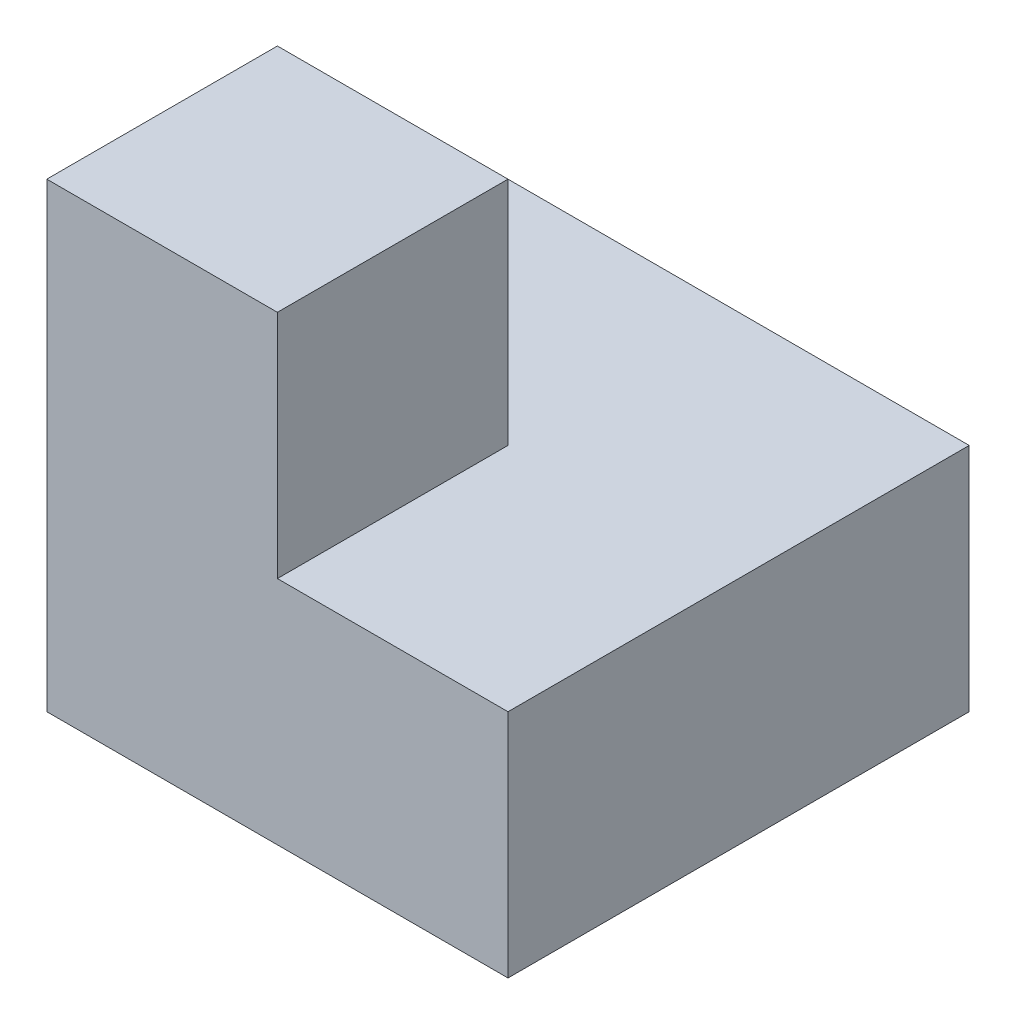
from build123d import *

# Parameters (mm, degrees)
SKETCH1_W           = 4
SKETCH1_H           = 4
BOSS_EXTRUDE1_DEPTH = 4
CUT_EXTRUDE1_DEPTH  = 2


with BuildPart() as part:
    # Sketch1 → Boss-Extrude1 (new body)
    with BuildSketch(Plane(origin=(0, 0, 0), x_dir=(1, 0, 0), z_dir=(0, 1, 0))):
        with Locations((2, 2)):
            Rectangle(SKETCH1_W, SKETCH1_H)
    extrude(amount=BOSS_EXTRUDE1_DEPTH)

    # Sketch2 → Cut-Extrude1 (cut)
    with BuildSketch(Plane(origin=(0, 4, 0), x_dir=(1, 0, 0), z_dir=(0, 1, 0))):
        Polygon((0, 4), (0, 2), (2, 2), (2, 0), (4, 0), (4, 4), align=None)
    extrude(amount=-CUT_EXTRUDE1_DEPTH, mode=Mode.SUBTRACT)


solid = part.part
